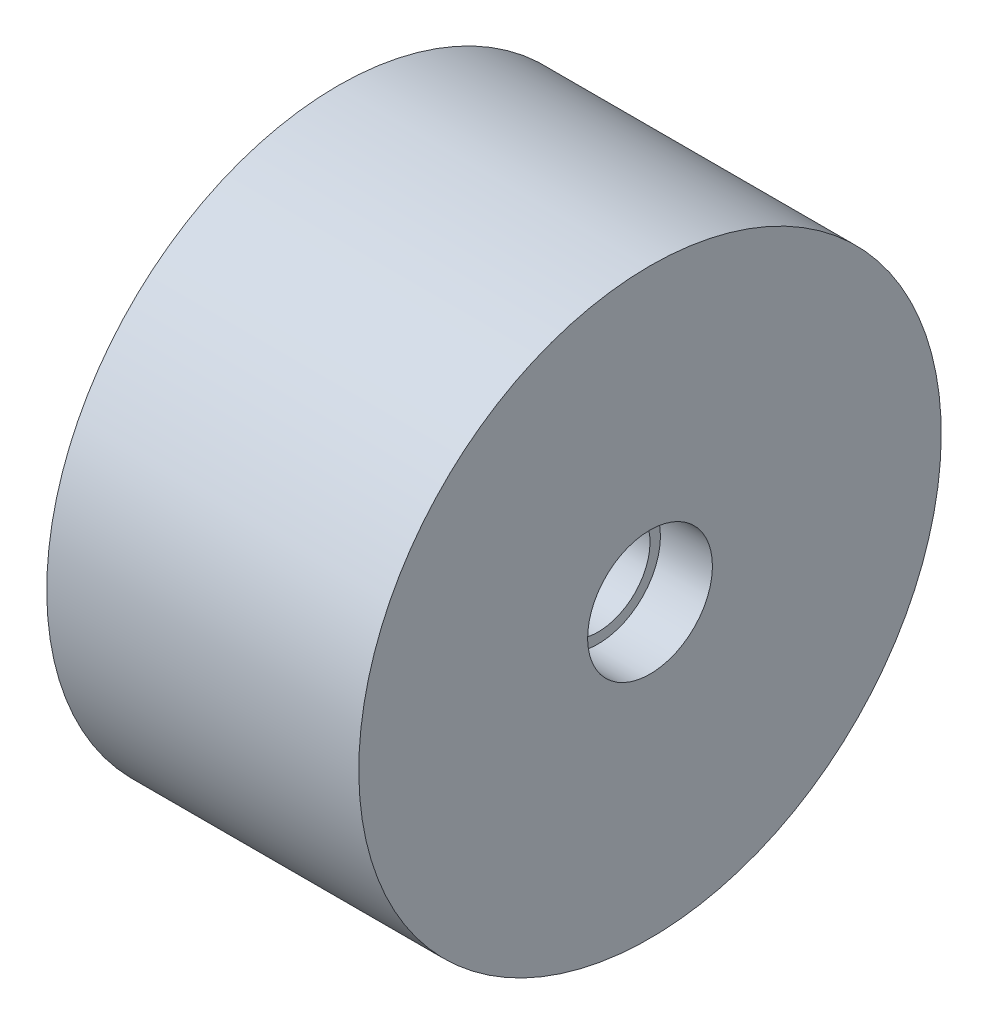
from build123d import *


with BuildPart() as part:
    # Sketch1 → Revolve1 (revolve)
    with BuildSketch(Plane.XY):
        Polygon((0, 17), (0, 28), (-15, 28), (-15, 27), (-1, 27), (-1, 18), (-14, 18), (-14, 17), (-12.45, 17), (-12.45, 16.5), (-2.5, 16.5), (-2.5, 17), align=None)
    revolve(axis=Axis((0.922761861, 14, 0), (-1, 0, 0)))


solid = part.part
